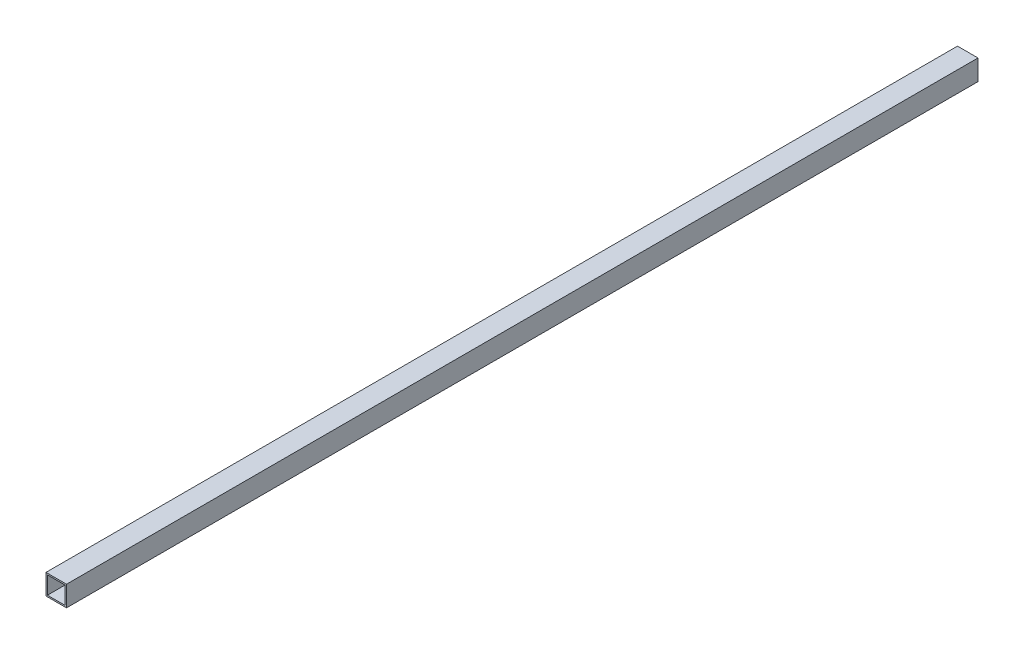
from build123d import *

# Parameters (mm, degrees)
SKETCH1_W           = 44.45
SKETCH1_H           = 44.45
SKETCH1_W_2         = 38.1
SKETCH1_H_2         = 38.1
BOSS_EXTRUDE1_DEPTH = 1974.85


with BuildPart() as part:
    # Sketch1 → Boss-Extrude1 (new body)
    with BuildSketch(Plane.XY):
        Rectangle(SKETCH1_W, SKETCH1_H)
        Rectangle(SKETCH1_W_2, SKETCH1_H_2, mode=Mode.SUBTRACT)
    extrude(amount=BOSS_EXTRUDE1_DEPTH)


solid = part.part
